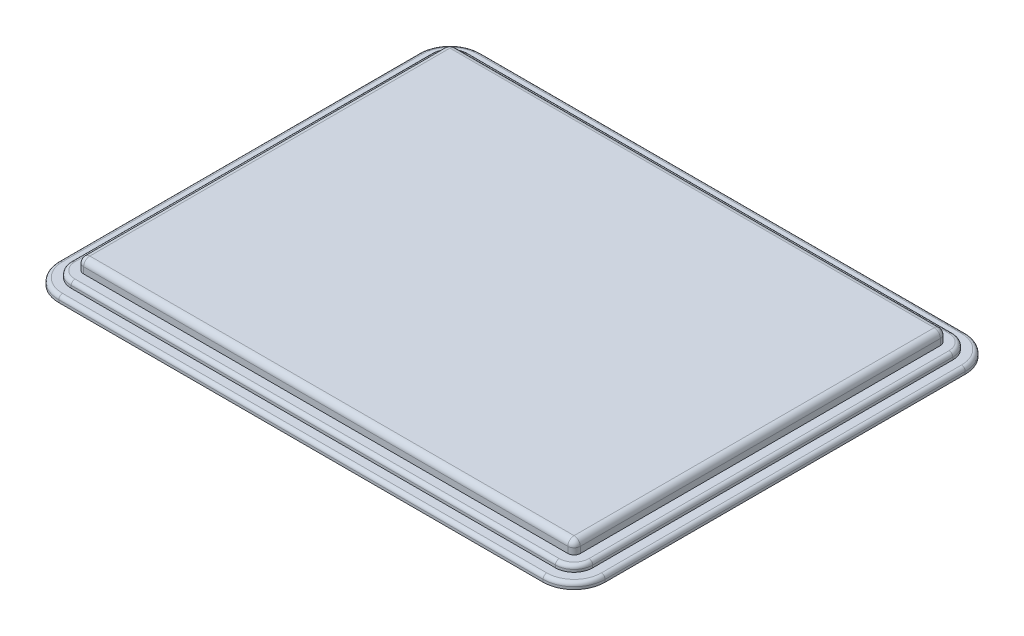
from build123d import *

# Parameters (mm, degrees)
BOSS_EXTRUDE1_DEPTH = 10
FILLET1_R           = 5
BOSS_EXTRUDE2_DEPTH = 5
BOSS_EXTRUDE3_DEPTH = 5
FILLET2_R           = 3


with BuildPart() as part:
    # Sketch1 → Boss-Extrude1 (new body)
    with BuildSketch(Plane(origin=(0, 0, 0), x_dir=(1, 0, 0), z_dir=(0, 1, 0))):
        with BuildLine():
            Line((-195, -150), (195, -150))
            ThreePointArc((195, -150), (198.535533906, -148.535533906), (200, -145))
            Line((200, -145), (200, 145))
            ThreePointArc((200, 145), (198.535533906, 148.535533906), (195, 150))
            Line((195, 150), (-195, 150))
            ThreePointArc((-195, 150), (-198.535533906, 148.535533906), (-200, 145))
            Line((-200, 145), (-200, -145))
            ThreePointArc((-200, -145), (-198.535533906, -148.535533906), (-195, -150))
        make_face()
    extrude(amount=BOSS_EXTRUDE1_DEPTH)

    # Fillet1
    fillet1_edges = [part.edges().sort_by_distance(p)[0] for p in [
        (198.535533906, 10, 148.535533906),
        (200, 10, 0),
        (198.535533906, 10, -148.535533906),
        (0, 10, -150),
        (-198.535533906, 10, -148.535533906),
        (-200, 10, 0),
        (-198.535533906, 10, 148.535533906),
        (0, 10, 150),
    ]]
    fillet(fillet1_edges, radius=FILLET1_R)


with BuildPart() as body_2:
    # Sketch4 → Boss-Extrude2 (new body)
    with BuildSketch(Plane.XZ):
        with BuildLine():
            Line((-210, 145), (-210, -145))
            ThreePointArc((-210, -145), (-205.606601718, -155.606601718), (-195, -160))
            Line((-195, -160), (195, -160))
            ThreePointArc((195, -160), (205.606601718, -155.606601718), (210, -145))
            Line((210, -145), (210, 145))
            ThreePointArc((210, 145), (205.606601718, 155.606601718), (195, 160))
            Line((195, 160), (-195, 160))
            ThreePointArc((-195, 160), (-205.606601718, 155.606601718), (-210, 145))
        make_face()
    extrude(amount=BOSS_EXTRUDE2_DEPTH)

    # Sketch5 → Boss-Extrude3 (add)
    with BuildSketch(Plane.XZ.offset(5)):
        with BuildLine():
            Line((-220, 145), (-220, -145))
            ThreePointArc((-220, -145), (-212.67766953, -162.67766953), (-195, -170))
            Line((-195, -170), (195, -170))
            ThreePointArc((195, -170), (212.67766953, -162.67766953), (220, -145))
            Line((220, -145), (220, 145))
            ThreePointArc((220, 145), (212.67766953, 162.67766953), (195, 170))
            Line((195, 170), (-195, 170))
            ThreePointArc((-195, 170), (-212.67766953, 162.67766953), (-220, 145))
        make_face()
    extrude(amount=BOSS_EXTRUDE3_DEPTH)

    # Fillet2
    fillet2_edges = [body_2.edges().sort_by_distance(p)[0] for p in [
        (0, 0, -160),
        (-205.606601718, 0, -155.606601718),
        (-210, 0, 0),
        (-205.606601718, 0, 155.606601718),
        (-212.67766953, -5, 162.67766953),
        (-220, -5, 0),
        (-212.67766953, -5, -162.67766953),
        (0, -5, -170),
        (212.67766953, -5, -162.67766953),
        (220, -5, 0),
        (212.67766953, -5, 162.67766953),
        (0, -5, 170),
        (0, 0, 160),
        (205.606601718, 0, 155.606601718),
        (210, 0, 0),
        (205.606601718, 0, -155.606601718),
    ]]
    fillet(fillet2_edges, radius=FILLET2_R)


solid = Compound([part.part, body_2.part])
